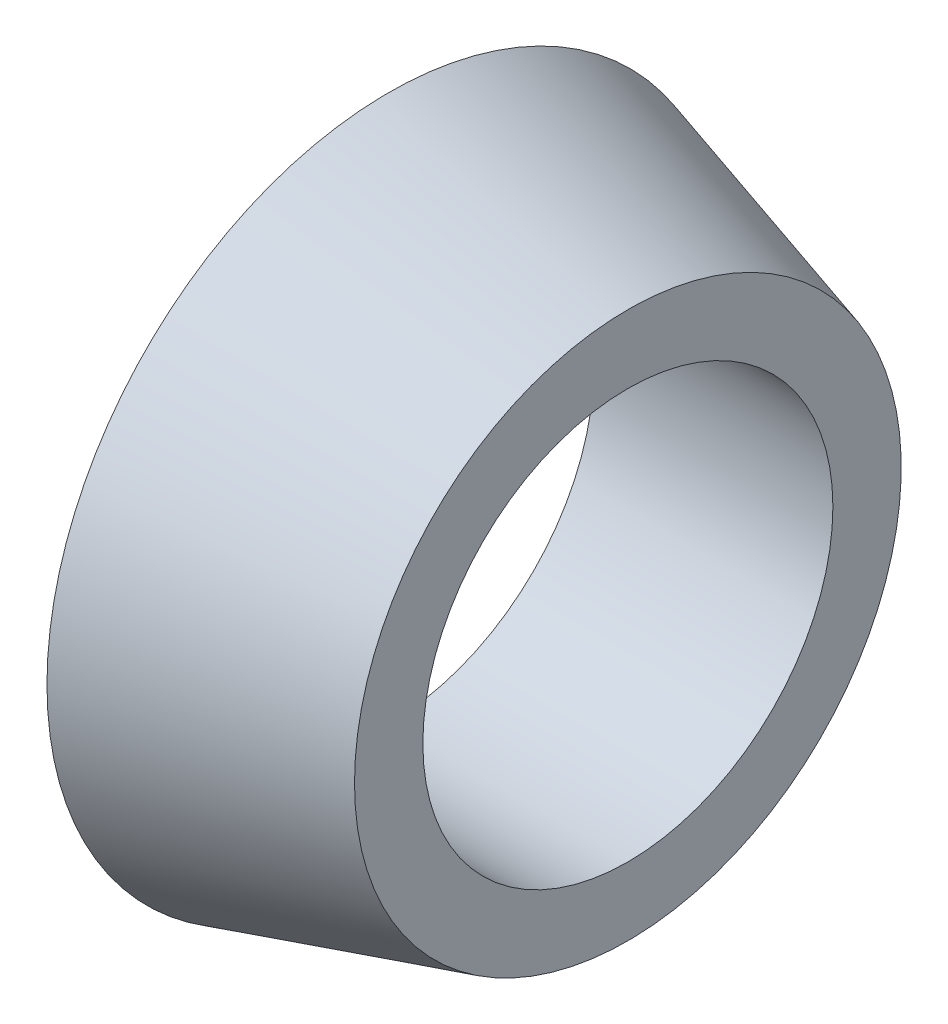
from build123d import *


with BuildPart() as part:
    # Szkic1 → Obrót1 (revolve)
    with BuildSketch(Plane.XY):
        Polygon((0, 6), (0, 10), (7, 8), (7, 6), align=None)
    revolve(axis=Axis((0, 0, 0), (1, 0, 0)))


solid = part.part
